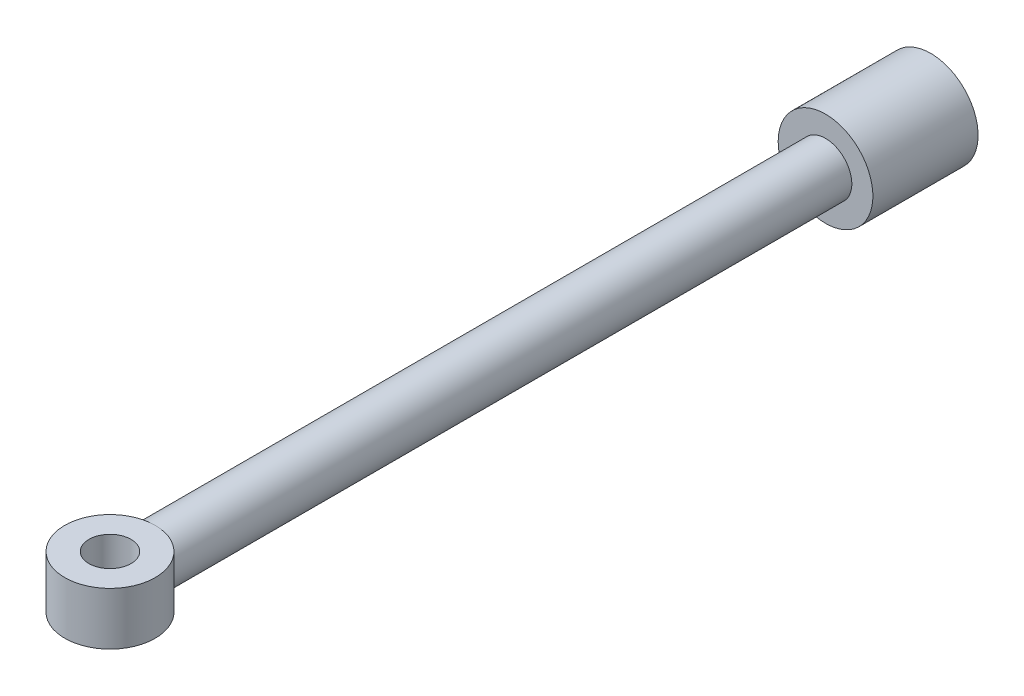
from build123d import *

# Parameters (mm, degrees)
SKETCH3_R           = 43
SKETCH3_R_2         = 20
BOSS_EXTRUDE1_DEPTH = 25


with BuildPart() as part:
    # Sketch1 → Revolve1 (revolve)
    with BuildSketch(Plane(origin=(0, 0, 0), x_dir=(1, 0, 0), z_dir=(0, 1, 0))):
        Polygon((0, -75), (45, -75), (45, -175), (25, -175), (25, -820.014288631), (0, -820.014288631), align=None)
    revolve(axis=Axis((0, 0, 75), (0, 0, 1)))

    # Sketch3 → Boss-Extrude1 (add, symmetric)
    with BuildSketch(Plane(origin=(0, 0, 0), x_dir=(1, 0, 0), z_dir=(0, 1, 0))):
        with Locations((0, -855)):
            Circle(SKETCH3_R)
        with Locations((0, -855)):
            Circle(SKETCH3_R_2, mode=Mode.SUBTRACT)
    extrude(amount=BOSS_EXTRUDE1_DEPTH, both=True)


solid = part.part
